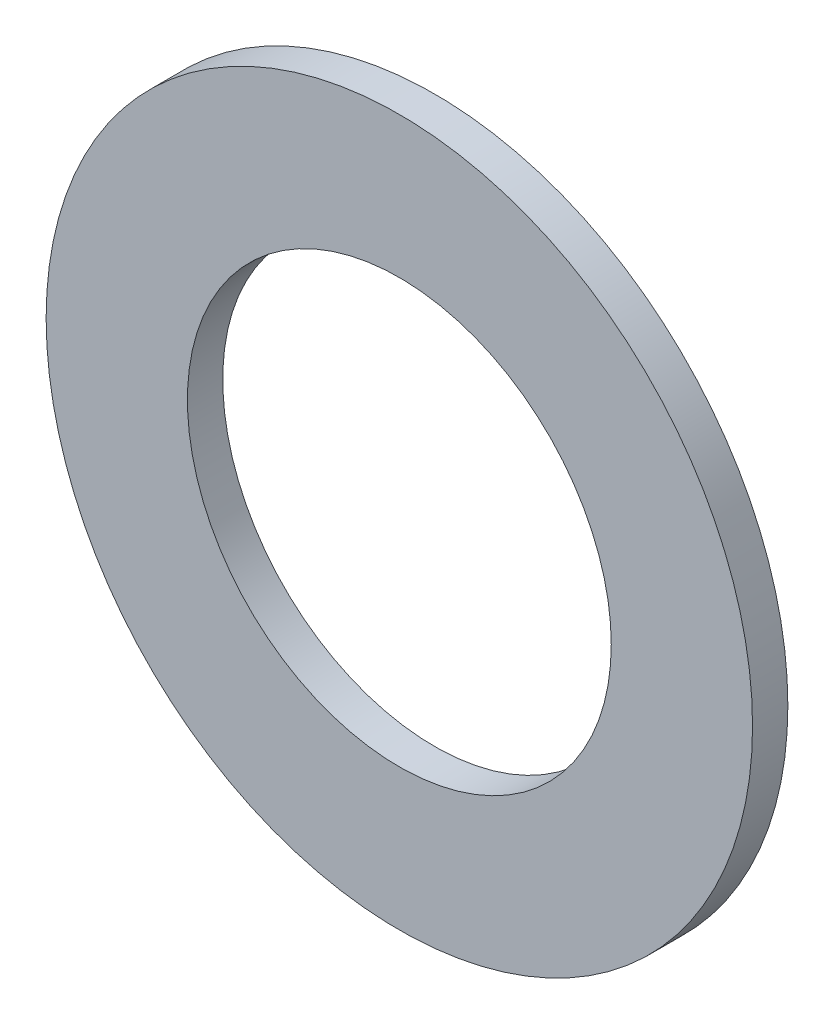
from build123d import *

# Parameters (mm, degrees)
SKETCH1_R           = 12.7
SKETCH1_R_2         = 7.62
BOSS_EXTRUDE1_DEPTH = 1.27


with BuildPart() as part:
    # Sketch1 → Boss-Extrude1 (new body)
    with BuildSketch(Plane.XY):
        Circle(SKETCH1_R)
        Circle(SKETCH1_R_2, mode=Mode.SUBTRACT)
    extrude(amount=BOSS_EXTRUDE1_DEPTH)


solid = part.part
